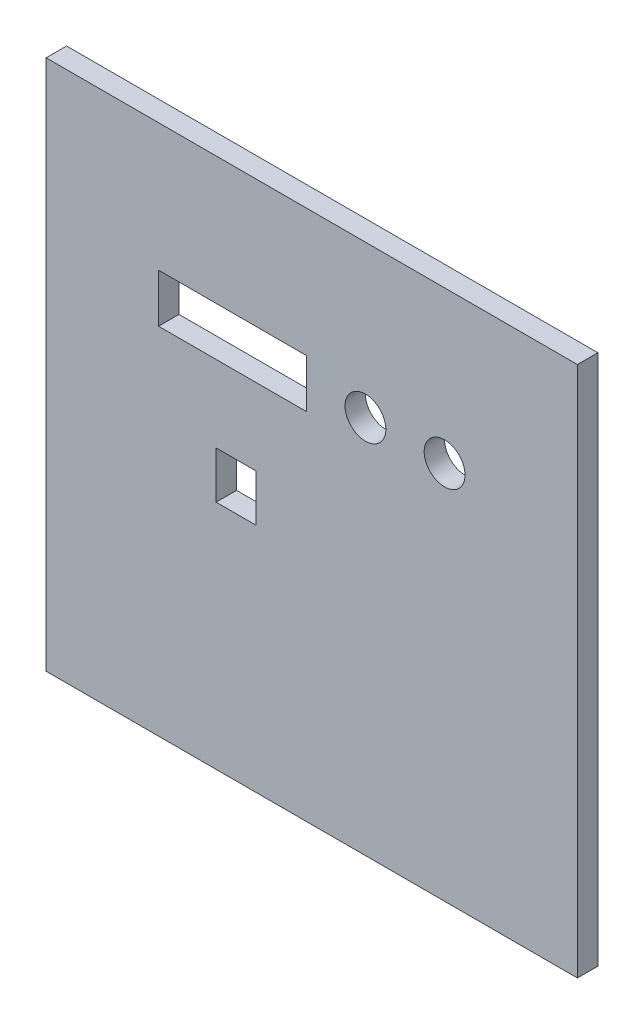
from build123d import *

# Parameters (mm, degrees)
SKETCH1_W           = 264.16
SKETCH1_H           = 264.16
BOSS_EXTRUDE1_DEPTH = 5.08
SKETCH2_R           = 10.16
SKETCH2_W           = 73.66
SKETCH2_H           = 24.13
SKETCH2_W_2         = 19.812
SKETCH2_H_2         = 23.368
CUT_EXTRUDE1_DEPTH  = 11.16


with BuildPart() as part:
    # Sketch1 → Boss-Extrude1 (new body, symmetric)
    with BuildSketch(Plane.XY):
        Rectangle(SKETCH1_W, SKETCH1_H)
    extrude(amount=BOSS_EXTRUDE1_DEPTH, both=True)

    # Sketch2 → Cut-Extrude1 (cut, through all)
    with BuildSketch(Plane.XY.offset(5.08)):
        with Locations((26.67, 56.515)):
            Circle(SKETCH2_R)
        with Locations((66.04, 56.515)):
            Circle(SKETCH2_R)
        with Locations((-39.37, 56.515)):
            Rectangle(SKETCH2_W, SKETCH2_H)
        with Locations((-37.662476274, -5.334)):
            Rectangle(SKETCH2_W_2, SKETCH2_H_2)
    extrude(amount=-CUT_EXTRUDE1_DEPTH, mode=Mode.SUBTRACT)


solid = part.part
